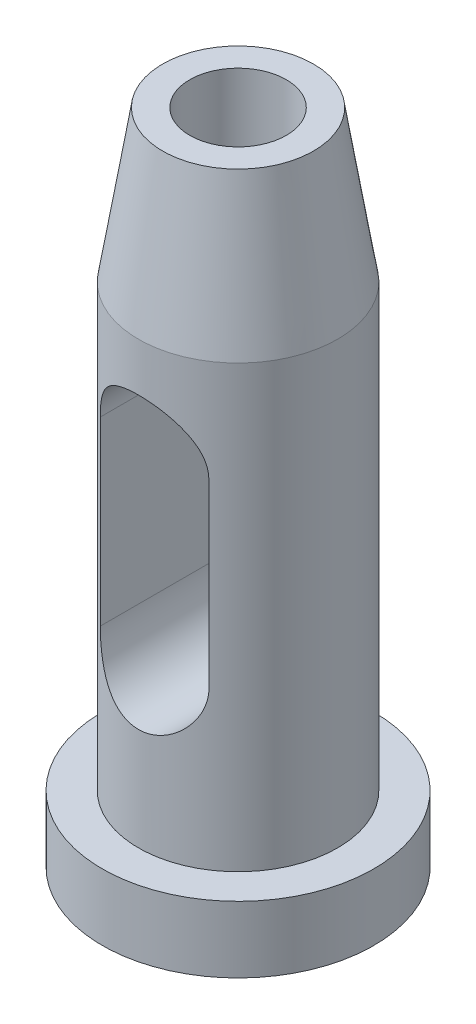
from build123d import *

# Parameters (mm, degrees)
CUT_EXTRUDE1_DEPTH      = 23.5
CUT_EXTRUDE1_DEPTH_BACK = 23.5
CUT_EXTRUDE2_REACH      = 111
SKETCH3_R               = 8


with BuildPart() as part:
    # Sketch1 → Revolve1 (revolve)
    with BuildSketch(Plane.XY):
        Polygon((0, 0), (22.5, 0), (22.5, 11), (16.5, 11), (16.5, 84), (12.5, 109), (0, 109), align=None)
    revolve(axis=Axis((0, 0, 0), (0, 1, 0)))

    # Sketch2 → Cut-Extrude1 (cut, two sides)
    with BuildSketch(Plane.XY) as cut_extrude1_sk:
        with BuildLine():
            Line((9, 67), (9, 37))
            ThreePointArc((9, 37), (0, 28), (-9, 37))
            Line((-9, 37), (-9, 67))
            ThreePointArc((-9, 67), (0, 76), (9, 67))
        make_face()
    extrude(amount=CUT_EXTRUDE1_DEPTH, mode=Mode.SUBTRACT)
    extrude(cut_extrude1_sk.sketch, amount=-CUT_EXTRUDE1_DEPTH_BACK, mode=Mode.SUBTRACT)

    # Sketch3 → Cut-Extrude2 (cut, up to next)
    with BuildSketch(Plane(origin=(0, 109, 0), x_dir=(1, 0, 0), z_dir=(0, 1, 0)), mode=Mode.PRIVATE) as cut_extrude2_sk1:
        Circle(SKETCH3_R)
    cut_extrude2_tool1 = extrude(cut_extrude2_sk1.sketch, amount=-CUT_EXTRUDE2_REACH, mode=Mode.PRIVATE) & part.part
    add(cut_extrude2_tool1.solids().sort_by_distance((0, 109, 0))[0], mode=Mode.SUBTRACT)


solid = part.part
